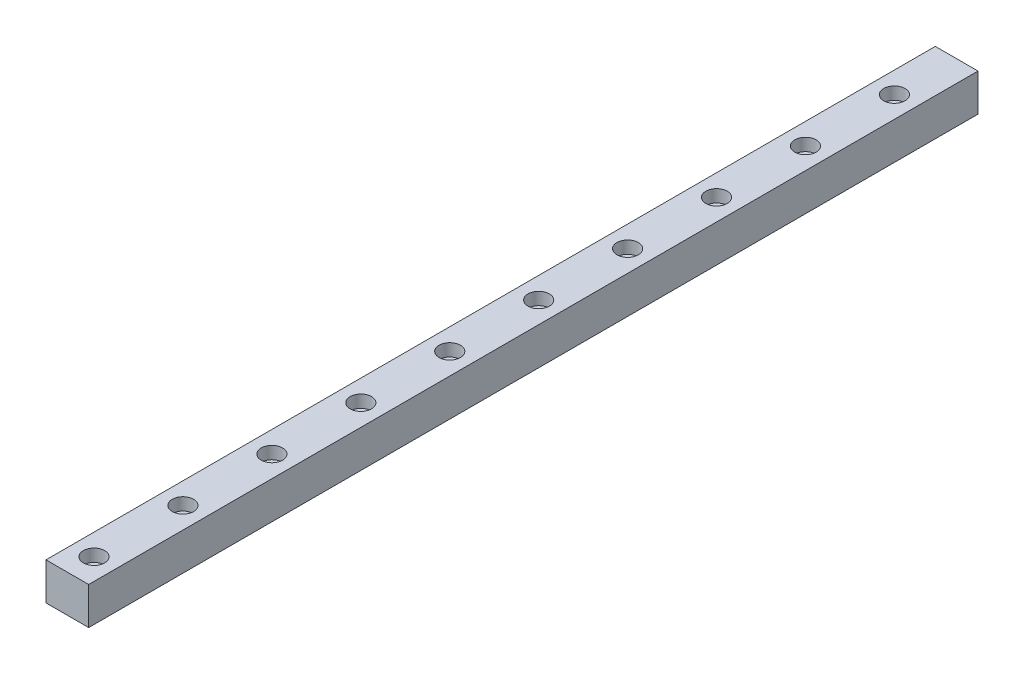
from build123d import *

# Parameters (mm, degrees)
SKETCH1_W           = 12
SKETCH1_H           = 10.5
BOSS_EXTRUDE1_DEPTH = 250
SKETCH2_R           = 3
CUT_EXTRUDE1_DEPTH  = 3.5
SKETCH3_R           = 1.75
CUT_EXTRUDE2_DEPTH  = 8
LPATTERN1_COUNT     = 12
LPATTERN1_PITCH     = 25


with BuildPart() as part:
    # Sketch1 → Boss-Extrude1 (new body)
    with BuildSketch(Plane.XY):
        with Locations((6, 5.25)):
            Rectangle(SKETCH1_W, SKETCH1_H)
    extrude(amount=BOSS_EXTRUDE1_DEPTH)

    # Sketch2 → Cut-Extrude1 (cut)
    with BuildSketch(Plane(origin=(0, 10.5, 0), x_dir=(1, 0, 0), z_dir=(0, 1, 0))):
        with Locations((6, -242.5)):
            Circle(SKETCH2_R)
    cut_extrude1 = extrude(amount=-CUT_EXTRUDE1_DEPTH, mode=Mode.SUBTRACT)

    # Sketch3 → Cut-Extrude2 (cut, through all)
    with BuildSketch(Plane(origin=(0, 7, 0), x_dir=(1, 0, 0), z_dir=(0, 1, 0))):
        with Locations((6, -242.5)):
            Circle(SKETCH3_R)
    cut_extrude2 = extrude(amount=-CUT_EXTRUDE2_DEPTH, mode=Mode.SUBTRACT)

    # LPattern1: Cut-Extrude1, Cut-Extrude2 ×12
    with Locations(*[(0, 0, -i * LPATTERN1_PITCH) for i in range(1, LPATTERN1_COUNT)]):
        add(cut_extrude1, mode=Mode.SUBTRACT)
        add(cut_extrude2, mode=Mode.SUBTRACT)


solid = part.part
